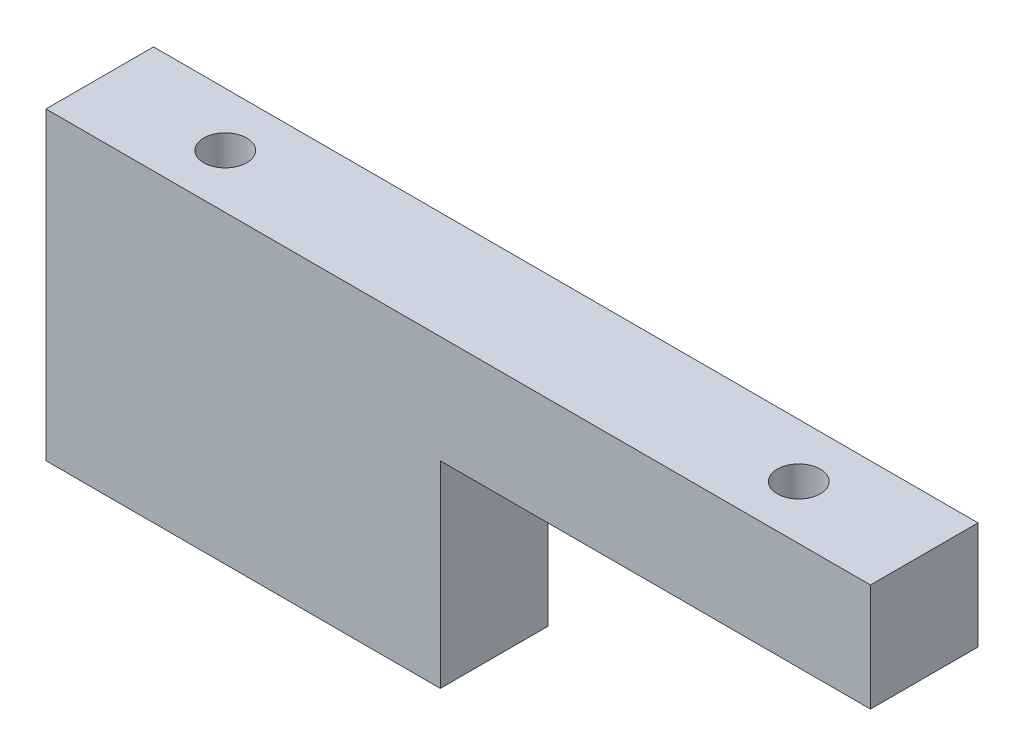
from build123d import *

# Parameters (mm, degrees)
SKETCH1_W                      = 115
SKETCH1_H                      = 15
BOSS_EXTRUDE1_DEPTH            = 42.5
SKETCH2_R                      = 3
CUT_EXTRUDE1_DEPTH             = 42.5
CUT_EXTRUDE2_REACH             = 17
SKETCH3_W                      = 60
SKETCH3_H                      = 27.5
CUT_EXTRUDE2_DIRECTION_2_DEPTH = 1


with BuildPart() as part:
    # Sketch1 → Boss-Extrude1 (new body)
    with BuildSketch(Plane(origin=(0, 0, 0), x_dir=(1, 0, 0), z_dir=(0, 1, 0))):
        Rectangle(SKETCH1_W, SKETCH1_H)
    extrude(amount=BOSS_EXTRUDE1_DEPTH)

    # Sketch2 → Cut-Extrude1 (cut)
    with BuildSketch(Plane(origin=(0, 42.5, 0), x_dir=(1, 0, 0), z_dir=(0, 1, 0))):
        with Locations((-40, 0)):
            Circle(SKETCH2_R)
        with Locations((40, 0)):
            Circle(SKETCH2_R)
    extrude(amount=-CUT_EXTRUDE1_DEPTH, mode=Mode.SUBTRACT)

    # Sketch3 → Cut-Extrude2 (cut, up to next)
    with BuildSketch(Plane.XY.offset(7.5), mode=Mode.PRIVATE) as cut_extrude2_sk1:
        with Locations((27.5, 13.75)):
            Rectangle(SKETCH3_W, SKETCH3_H)
    cut_extrude2_tool1 = extrude(cut_extrude2_sk1.sketch, amount=-CUT_EXTRUDE2_REACH, mode=Mode.PRIVATE) & part.part
    add(cut_extrude2_tool1.solids().sort_by_distance((27.5, 13.75, 7.5))[0], mode=Mode.SUBTRACT)

    # Sketch3 → Cut-Extrude2 direction 2 (cut)
    with BuildSketch(Plane.XY.offset(7.5)):
        with Locations((27.5, 13.75)):
            Rectangle(SKETCH3_W, SKETCH3_H)
    extrude(amount=CUT_EXTRUDE2_DIRECTION_2_DEPTH, mode=Mode.SUBTRACT)


solid = part.part
